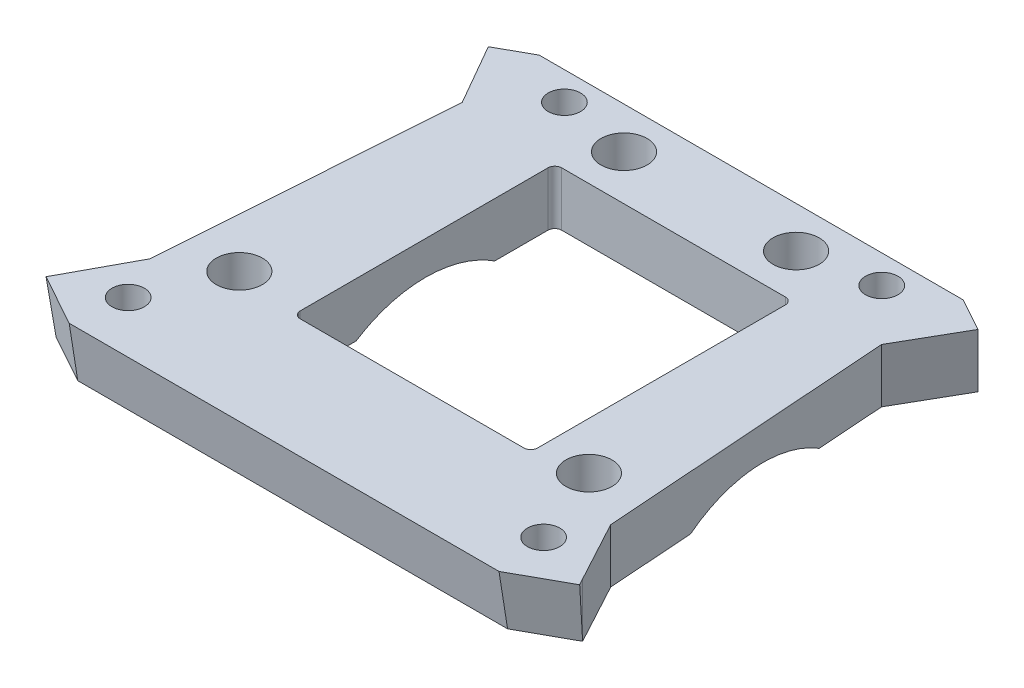
from build123d import *

# Parameters (mm, degrees)
BOSS_EXTRUDE1_DEPTH      = 10
CUT_EXTRUDE1_DEPTH       = 39.246851426
CUT_EXTRUDE1_DEPTH_BACK  = 39.246851426
BOSS_EXTRUDE2_DEPTH      = 31.226887
BOSS_EXTRUDE2_DEPTH_BACK = 31.226887
BOSS_EXTRUDE4_DEPTH      = 7.852901
CUT_EXTRUDE6_REACH       = 15.474
BOSS_EXTRUDE6_DEPTH      = 7.852901
CUT_EXTRUDE7_REACH       = 15.474
SKETCH15_W               = 34.5
SKETCH15_H               = 38
CUT_EXTRUDE8_DEPTH       = 8.852900758
FILLET1_R                = 1
SKETCH16_R               = 2.35
CUT_EXTRUDE9_DEPTH       = 7.852901
SKETCH18_R               = 3.35
CUT_EXTRUDE10_DEPTH      = 7.852901
CUT_EXTRUDE11_DEPTH      = 55.774002508
CUT_EXTRUDE11_DEPTH_BACK = 23.774002507


with BuildPart() as part:
    # Sketch1 → Boss-Extrude1 (new body)
    with BuildSketch(Plane(origin=(0, 0, 0), x_dir=(1, 0, 0), z_dir=(0, 1, 0))):
        Polygon((28.55688655, 32.59875814), (-28.55688655, 32.59875814), (-35.576851431, 28.714212738), (-30.467341853, 19.813019987), (-33.461967186, -22.544744449), (-38.246851426, -31.408872502), (-31.226886544, -35.293417903), (31.226886544, -35.293417903), (38.246851426, -31.408872502), (33.461967186, -22.544744449), (30.467341853, 19.813019987), (35.576851431, 28.714212738), align=None)
    extrude(amount=BOSS_EXTRUDE1_DEPTH)

    # Sketch3 → Cut-Extrude1 (cut, two sides)
    with BuildSketch(Plane(origin=(0, 0, 0), x_dir=(0, 0, -1), z_dir=(1, 0, 0))) as cut_extrude1_sk:
        Polygon((31.354413252, 7.852900712), (32.59875814, 0), (34.072271083, 0), (34.072271083, 12.681172501), (31.434287212, 12.681172501), (-35.293417903, 12.681172501), (-35.293417903, 10), (-35.293417903, 7.852900712), align=None)
    extrude(amount=CUT_EXTRUDE1_DEPTH, mode=Mode.SUBTRACT)
    extrude(cut_extrude1_sk.sketch, amount=-CUT_EXTRUDE1_DEPTH_BACK, mode=Mode.SUBTRACT)

    # Sketch5 → Boss-Extrude2 (add, two sides)
    with BuildSketch(Plane(origin=(0, 0, 0), x_dir=(0, 0, -1), z_dir=(1, 0, 0))) as boss_extrude2_sk:
        Polygon((-35.29341791, 0), (-35.293417904, 7.852900712), (-36.537762798, 7.852900712), align=None)
    extrude(amount=BOSS_EXTRUDE2_DEPTH)
    extrude(boss_extrude2_sk.sketch, amount=-BOSS_EXTRUDE2_DEPTH_BACK)

    # Sketch7 → Boss-Extrude4 (add)
    with BuildSketch(Plane(origin=(0, 7.852900712, 0), x_dir=(1, 0, 0), z_dir=(0, 1, 0))):
        Polygon((31.226886544, -35.293417903), (38.246851426, -31.408872502), (38.774002508, -32.361514754), (31.226886544, -36.537762798), align=None)
    extrude(amount=-BOSS_EXTRUDE4_DEPTH)

    # Cut-Extrude6: up to this face of the body (flat: up to its plane)
    cut_extrude6_end = Plane(part.part.faces().sort_by_distance((0.070807589, 7.852900712, 3.202963046))[0])
    # Sketch12 → Cut-Extrude6 (cut, up to the picked face)
    with BuildSketch(Plane(origin=(0, 0, 0), x_dir=(1, 0, 0), z_dir=(0, 0.987677308, 0.156504106)), mode=Mode.PRIVATE) as cut_extrude6_sk1:
        Polygon((30.896216351, -36.268243015), (31.226886544, -36.087519199), (38.774002508, -31.962733774), (39.457900831, -31.588957374), (38.940691815, -30.642620529), (31.226886544, -34.85850799), (30.896216351, -34.85850799), align=None)
    cut_extrude6_tool1 = split(extrude(cut_extrude6_sk1.sketch, amount=CUT_EXTRUDE6_REACH, mode=Mode.PRIVATE), bisect_by=cut_extrude6_end, keep=Keep.BOTH, mode=Mode.PRIVATE)
    add(cut_extrude6_tool1.solids().sort_by_distance((35.037296, -5.226434, 32.983357))[0], mode=Mode.SUBTRACT)

    # Sketch13 → Boss-Extrude6 (add)
    with BuildSketch(Plane(origin=(0, 7.852900712, 0), x_dir=(1, 0, 0), z_dir=(0, 1, 0))):
        Polygon((-31.226886544, -35.293417904), (-31.226886544, -36.537762798), (-38.774002507, -32.361514753), (-38.246851426, -31.408872502), align=None)
    extrude(amount=-BOSS_EXTRUDE6_DEPTH)

    # Cut-Extrude7: up to this face of the body (flat: up to its plane)
    cut_extrude7_end = Plane(part.part.faces().sort_by_distance((0, 7.852900712, 3.265184411))[0])
    # Sketch14 → Cut-Extrude7 (cut, up to the picked face)
    with BuildSketch(Plane(origin=(0, 0, 0), x_dir=(1, 0, 0), z_dir=(0, 0.987677308, 0.156504106)), mode=Mode.PRIVATE) as cut_extrude7_sk1:
        Polygon((-38.774002507, -31.962733773), (-31.226886544, -36.087519199), (-31.226886544, -34.858507985), (-39.138580492, -30.534466847), (-40.986059535, -30.753760618), align=None)
    cut_extrude7_tool1 = split(extrude(cut_extrude7_sk1.sketch, amount=CUT_EXTRUDE7_REACH, mode=Mode.PRIVATE), bisect_by=cut_extrude7_end, keep=Keep.BOTH, mode=Mode.PRIVATE)
    add(cut_extrude7_tool1.solids().sort_by_distance((-35.660699, -5.175776, 32.663656))[0], mode=Mode.SUBTRACT)

    # Sketch15 → Cut-Extrude8 (cut, through all)
    with BuildSketch(Plane(origin=(0, 7.852900712, 0), x_dir=(1, 0, 0), z_dir=(0, 1, 0))):
        with Locations((1.25, -0.19872767)):
            Rectangle(SKETCH15_W, SKETCH15_H)
    extrude(amount=-CUT_EXTRUDE8_DEPTH, mode=Mode.SUBTRACT)

    # Fillet1
    fillet1_edges = [part.edges().sort_by_distance(p)[0] for p in [
        (-16, 3.926450356, 19.19872767),
        (-16, 3.926450356, -18.80127233),
        (18.5, 3.926450356, -18.80127233),
        (18.5, 3.926450356, 19.19872767),
    ]]
    fillet(fillet1_edges, radius=FILLET1_R)

    # Sketch16 → Cut-Extrude9 (cut)
    with BuildSketch(Plane(origin=(0, 7.852900712, 0), x_dir=(1, 0, 0), z_dir=(0, 1, 0))):
        with BuildLine():
            ThreePointArc((-23.169283502, 24.901447562), (-23.167136672, 24.901345749), (-23.16498975, 24.901245899))
            ThreePointArc((-23.16498975, 24.901245899), (-21.433855825, 25.549266666), (-20.706886553, 27.248758135))
            ThreePointArc((-20.706886553, 27.248758135), (-24.678362296, 28.949733272), (-23.169283502, 24.901447563))
        make_face()
        with Locations((-30.183959547, -29.01317237)):
            Circle(SKETCH16_R)
        with Locations((30.183959554, -29.013172365)):
            Circle(SKETCH16_R)
        with BuildLine():
            ThreePointArc((23.164989747, 24.901245903), (23.167136669, 24.901345753), (23.169283499, 24.901447567))
            ThreePointArc((23.169283499, 24.901447567), (24.757861687, 25.627282396), (25.40688655, 27.24875814))
            ThreePointArc((25.40688655, 27.24875814), (21.357395081, 28.871788867), (23.164989747, 24.901245903))
        make_face()
    extrude(amount=-CUT_EXTRUDE9_DEPTH, mode=Mode.SUBTRACT)

    # Sketch18 → Cut-Extrude10 (cut)
    with BuildSketch(Plane(origin=(0, 7.852900712, 0), x_dir=(1, 0, 0), z_dir=(0, 1, 0))):
        with Locations((-25.397590164, -17.646835853)):
            Circle(SKETCH18_R)
        with Locations((12.500295063, 25.355028006)):
            Circle(SKETCH18_R)
        with Locations((-12.499704907, 25.353798513)):
            Circle(SKETCH18_R)
        with Locations((25.402409775, -17.644337524)):
            Circle(SKETCH18_R)
    extrude(amount=-CUT_EXTRUDE10_DEPTH, mode=Mode.SUBTRACT)

    # Sketch19 → Cut-Extrude11 (cut, two sides)
    with BuildSketch(Plane(origin=(-16, 0, 0), x_dir=(0, 0, -1), z_dir=(1, 0, 0))) as cut_extrude11_sk:
        with BuildLine():
            Line((-10.0632786, 0), (10.065144671, 0))
            add(Edge.make_bspline(
                [(0.000933035, 2.967511147), (0.544521725, 2.967511147), (1.619583471, 2.921196479), (3.854022546, 2.625629399), (6.684377205, 1.845878396), (8.927393688, 0.727415261), (10.014615597, 0.032640048), (10.065144671, 0)],
                knots=[0, 0, 0, 0, 0.0625, 0.125, 0.25, 0.375, 0.381109812, 0.381109812, 0.381109812, 0.381109812], degree=3))
            add(Edge.make_bspline(
                [(0.000933035, 2.967511147), (-0.542655654, 2.967511147), (-1.6177174, 2.921196479), (-3.852156475, 2.625629399), (-6.682511135, 1.845878396), (-8.925527618, 0.727415261), (-10.012749527, 0.032640048), (-10.0632786, 0)],
                knots=[0, 0, 0, 0, 0.0625, 0.125, 0.25, 0.375, 0.381109812, 0.381109812, 0.381109812, 0.381109812], degree=3))
        make_face()
    extrude(amount=CUT_EXTRUDE11_DEPTH, mode=Mode.SUBTRACT)
    extrude(cut_extrude11_sk.sketch, amount=-CUT_EXTRUDE11_DEPTH_BACK, mode=Mode.SUBTRACT)


solid = part.part
